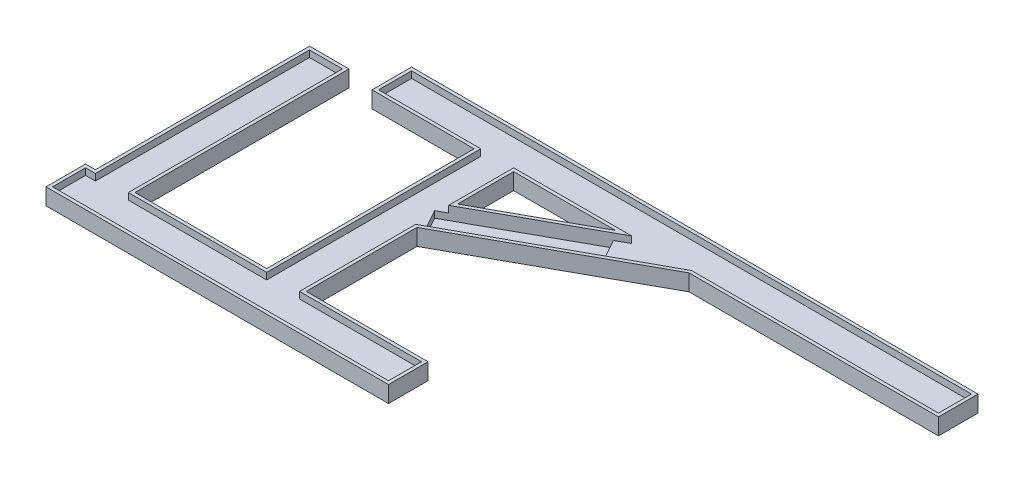
from build123d import *

# Parameters (mm, degrees)
SKETCH_3_W           = 10
SKETCH_3_H           = 65
SKETCH_3_W_2         = 85
SKETCH_3_H_2         = 10
EXTRUDE_2_DEPTH      = 1
EXTRUDE_3_DEPTH      = 4
EXTRUDE_3_DEPTH_BACK = 1
EXTRUDE_4_DEPTH      = 2
SKETCH_7_W           = 10
SKETCH_7_H           = 12
CUT_EXTRUDE_1_DEPTH  = 5
SKETCH_8_W           = 1
SKETCH_8_H           = 10
EXTRUDE_5_DEPTH      = 2
SKETCH_9_W           = 10
SKETCH_9_H           = 12
EXTRUDE_7_DEPTH      = 5
SKETCH_10_W          = 10
SKETCH_10_H          = 10
CUT_EXTRUDE_2_DEPTH  = 2


with BuildPart() as part:
    # 草图3 → 凸台-拉伸2 (new body)
    with BuildSketch(Plane(origin=(0, 0, 0), x_dir=(1, 0, 0), z_dir=(0, 1, 0))):
        with Locations((-68.5, -37.5)):
            Rectangle(SKETCH_3_W, SKETCH_3_H)
        Polygon((25.5, -70), (-11.5, -70), (-21.5, -70), (-63.5, -70), (-73.5, -70), (-76.5, -70), (-76.5, -80), (25.5, -80), align=None)
        Polygon((-11.5, -70), (-11.5, -34.745762712), (-16.5, -37.5), (-16.5, -27.5), (-11.5, -24.745762712), (-11.5, -5), (-21.5, -5), (-21.5, -70), align=None)
        Polygon((24.346153846, -5), (42.5, 5), (-42.5, 5), (-42.5, -5), (-21.5, -5), (-11.5, -5), align=None)
        with Locations((85, 0)):
            Rectangle(SKETCH_3_W_2, SKETCH_3_H_2)
        Polygon((24.346153846, -5), (42.5, -5), (42.5, 5), align=None)
        Polygon((-11.5, -34.745762712), (42.5, -5), (24.346153846, -5), (-11.5, -24.745762712), align=None)
        Polygon((-16.5, -37.5), (-11.5, -34.745762712), (-11.5, -24.745762712), (-16.5, -27.5), align=None)
    extrude(amount=EXTRUDE_2_DEPTH)

    # 草图4 → 凸台-拉伸3 (add, two sides)
    with BuildSketch(Plane(origin=(0, 1, 0), x_dir=(1, 0, 0), z_dir=(0, 1, 0))) as extrude_3_sk:
        Polygon((26.5, -69), (-10.5, -69), (-10.5, -35.336595122), (42.757203453, -6), (128.5, -6), (128.5, 6), (-43.5, 6), (-43.5, -6), (-22.5, -6), (-22.5, -69), (-62.5, -69), (-62.5, -4), (-74.5, -4), (-74.5, -69), (-77.5, -69), (-77.5, -81), (26.5, -81), align=None)
        Polygon((-11.5, -34.745762712), (42.5, -5), (127.5, -5), (127.5, 5), (-42.5, 5), (-42.5, -5), (-21.5, -5), (-21.5, -70), (-63.5, -70), (-63.5, -5), (-73.5, -5), (-73.5, -70), (-76.5, -70), (-76.5, -80), (25.5, -80), (25.5, -70), (-11.5, -70), align=None, mode=Mode.SUBTRACT)
        Polygon((-11.5, -5), (24.346153846, -5), (-11.5, -24.745762712), align=None)
        Polygon((-10.5, -23.053235386), (20.458181162, -6), (-10.5, -6), align=None, mode=Mode.SUBTRACT)
    extrude(amount=EXTRUDE_3_DEPTH)
    extrude(extrude_3_sk.sketch, amount=-EXTRUDE_3_DEPTH_BACK)

    # 草图5 → 凸台-拉伸4 (add)
    with BuildSketch(Plane(origin=(0, 1, 0), x_dir=(1, 0, 0), z_dir=(0, 1, 0))):
        Polygon((-10.007424518, -33.923581302), (-14.233552679, -26.251533255), (-11.5, -24.745762712), (-11.5, -5), (24.346153846, -5), (20.802538534, -6.951991486), (25.028666695, -14.624039532), (42.5, -5), (127.5, -5), (127.5, 5), (-42.5, 5), (-42.5, -5), (-21.5, -5), (-21.5, -70), (-63.5, -70), (-63.5, -5), (-73.5, -5), (-73.5, -70), (-76.5, -70), (-76.5, -80), (25.5, -80), (25.5, -70), (-11.5, -70), (-11.5, -34.745762712), align=None)
    extrude(amount=EXTRUDE_4_DEPTH)

    # 草图7 → 切除-拉伸1 (cut)
    with BuildSketch(Plane(origin=(0, 5, 0), x_dir=(1, 0, 0), z_dir=(0, 1, 0))):
        with Locations((123.5, 0)):
            Rectangle(SKETCH_7_W, SKETCH_7_H)
    extrude(amount=-CUT_EXTRUDE_1_DEPTH, mode=Mode.SUBTRACT)

    # 草图8 → 凸台-拉伸5 (add)
    with BuildSketch(Plane(origin=(0, 3, 0), x_dir=(1, 0, 0), z_dir=(0, 1, 0))):
        with Locations((118, 0)):
            Rectangle(SKETCH_8_W, SKETCH_8_H)
    extrude(amount=EXTRUDE_5_DEPTH)

    # 草图9 → 凸台-拉伸7 (add)
    with BuildSketch(Plane(origin=(0, 5, 0), x_dir=(1, 0, 0), z_dir=(0, 1, 0))):
        with Locations((-48.5, 0)):
            Rectangle(SKETCH_9_W, SKETCH_9_H)
    extrude(amount=-EXTRUDE_7_DEPTH)

    # 草图10 → 切除-拉伸2 (cut)
    with BuildSketch(Plane(origin=(0, 5, 0), x_dir=(1, 0, 0), z_dir=(0, 1, 0))):
        with Locations((-47.5, 0)):
            Rectangle(SKETCH_10_W, SKETCH_10_H)
    extrude(amount=-CUT_EXTRUDE_2_DEPTH, mode=Mode.SUBTRACT)


solid = part.part
